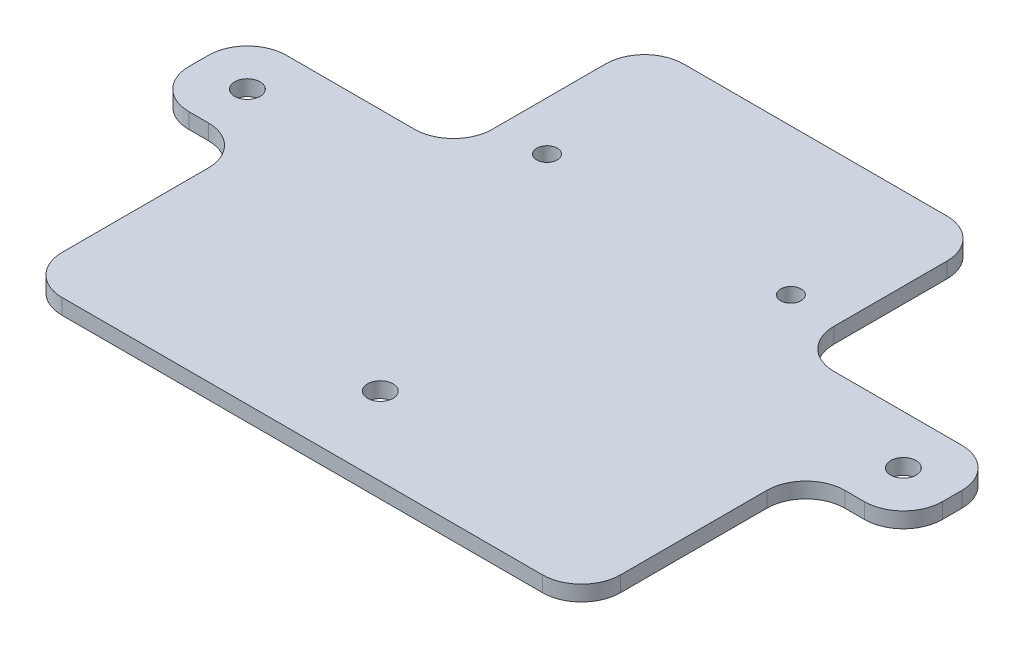
from build123d import *

# Parameters (mm, degrees)
SKETCH3_R           = 2.1
SKETCH3_R_2         = 2.6
BOSS_EXTRUDE1_DEPTH = 3.175
FILLET1_R           = 8


with BuildPart() as part:
    # Sketch3 → Boss-Extrude1 (new body)
    with BuildSketch(Plane(origin=(0, 0, 0), x_dir=(1, 0, 0), z_dir=(0, 1, 0))):
        Polygon((-35, -45), (35, -45), (35, -84.175), (77.25, -84.175), (77.25, -104.175), (57.25, -104.175), (57.25, -150.175), (-57.25, -150.175), (-57.25, -104.175), (-77.25, -104.175), (-77.25, -84.175), (-35, -84.175), align=None)
        with Locations((-25, -75)):
            Circle(SKETCH3_R, mode=Mode.SUBTRACT)
        with Locations((25, -75)):
            Circle(SKETCH3_R, mode=Mode.SUBTRACT)
        with Locations((-67.25, -94.175)):
            Circle(SKETCH3_R_2, mode=Mode.SUBTRACT)
        with Locations((67.25, -94.175)):
            Circle(SKETCH3_R_2, mode=Mode.SUBTRACT)
        with Locations((0, -134.175)):
            Circle(SKETCH3_R_2, mode=Mode.SUBTRACT)
    extrude(amount=BOSS_EXTRUDE1_DEPTH)

    # Fillet1
    fillet1_edges = [part.edges().sort_by_distance(p)[0] for p in [
        (35, 1.5875, 84.175),
        (77.25, 1.5875, 84.175),
        (77.25, 1.5875, 104.175),
        (57.25, 1.5875, 104.175),
        (57.25, 1.5875, 150.175),
        (-57.25, 1.5875, 150.175),
        (-57.25, 1.5875, 104.175),
        (-77.25, 1.5875, 104.175),
        (-77.25, 1.5875, 84.175),
        (-35, 1.5875, 84.175),
        (-35, 1.5875, 45),
        (35, 1.5875, 45),
    ]]
    fillet(fillet1_edges, radius=FILLET1_R)


solid = part.part
